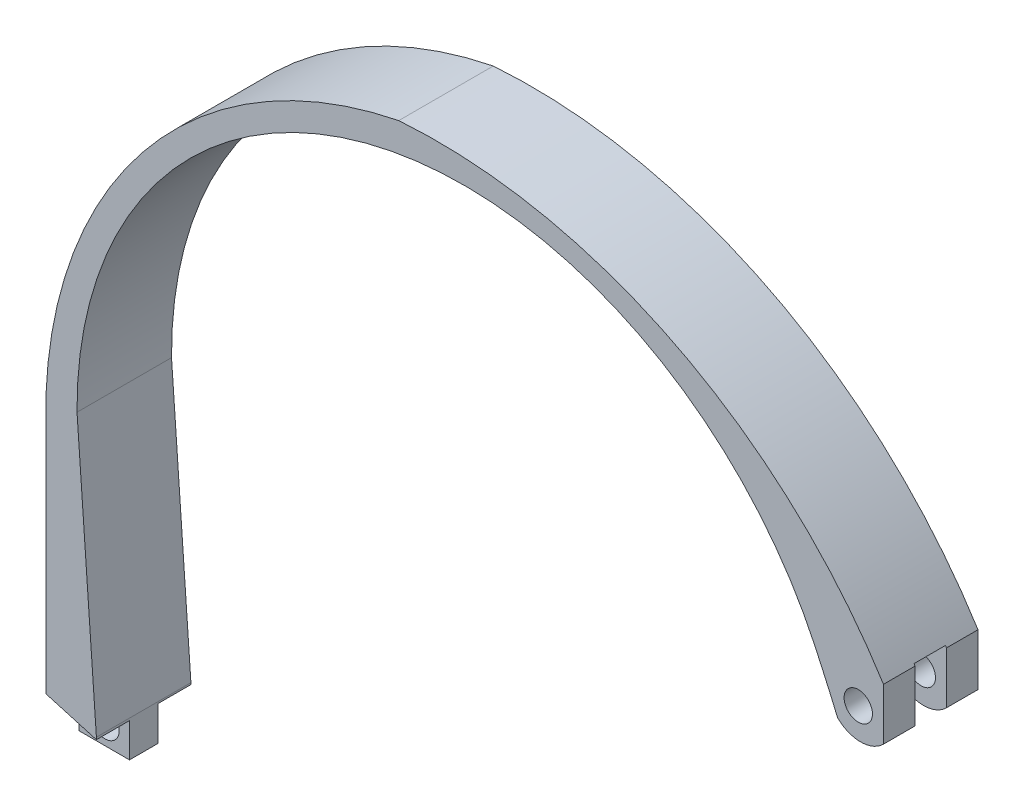
from build123d import *

# Parameters (mm, degrees)
SKETCH3_R           = 2.25
BOSS_EXTRUDE1_DEPTH = 15
CUT_EXTRUDE2_DEPTH  = 5.25
CUT_EXTRUDE3_DEPTH  = 5.25
SKETCH9_W           = 4.986330716
SKETCH9_H           = 10
CUT_EXTRUDE4_DEPTH  = 20


with BuildPart() as part:
    # Sketch3 → Boss-Extrude1 (new body)
    with BuildSketch(Plane.XY):
        with BuildLine():
            Line((-83.240837696, 45.680087808), (-86.318243263, 88.806933971))
            ThreePointArc((-86.318243263, 88.806933971), (-38.505178909, 149.199689366), (30.717635907, 115.412473794))
            ThreePointArc((30.717635907, 115.412473794), (32.594544712, 111.314313071), (34.392132503, 107.180744866))
            ThreePointArc((34.392132503, 107.180744866), (38.03694462, 105.671014255), (41.681756737, 107.180744866))
            Line((41.681756737, 107.180744866), (41.681756737, 115.412473794))
            ThreePointArc((41.681756737, 115.412473794), (8.630903534, 145.599759454), (-35.251645513, 154.428859194))
            ThreePointArc((-35.251645513, 154.428859194), (-74.611345825, 131.314701457), (-91.240837696, 88.806933971))
            Line((-91.240837696, 88.806933971), (-91.240837696, 47.654450262))
            Line((-91.240837696, 47.654450262), (-91.240837696, 39.931378559))
            Line((-91.240837696, 39.931378559), (-83.240837696, 39.931378559))
            Line((-83.240837696, 39.931378559), (-83.240837696, 45.680087808))
        make_face()
        with Locations((-87.125618482, 43.130480477)):
            Circle(SKETCH3_R, mode=Mode.SUBTRACT)
        with Locations((37.681756737, 110.446980465)):
            Circle(SKETCH3_R, mode=Mode.SUBTRACT)
    extrude(amount=-BOSS_EXTRUDE1_DEPTH)

    # Sketch5 → Cut-Extrude2 (cut)
    with BuildSketch(Plane.XY):
        Polygon((-91.240837696, 47.634728669), (-83.240837696, 45.336049347), (-83.240837696, 39.931378559), (-91.240837696, 39.931378559), align=None)
    extrude(amount=-CUT_EXTRUDE2_DEPTH, mode=Mode.SUBTRACT)

    # Sketch8 → Cut-Extrude3 (cut)
    with BuildSketch(Plane(origin=(0, 0, -15), x_dir=(-1, 0, 0), z_dir=(0, 0, -1))):
        Polygon((91.240837696, 47.718881947), (83.240837696, 45.410478658), (83.240837696, 39.931378559), (91.240837696, 39.931378559), align=None)
    extrude(amount=-CUT_EXTRUDE3_DEPTH, mode=Mode.SUBTRACT)

    # Sketch9 → Cut-Extrude4 (cut)
    with BuildSketch(Plane(origin=(41.681756737, 0, 0), x_dir=(0, 0, -1), z_dir=(1, 0, 0))):
        with Locations((7.506834642, 110.671014255)):
            Rectangle(SKETCH9_W, SKETCH9_H)
    extrude(amount=-CUT_EXTRUDE4_DEPTH, mode=Mode.SUBTRACT)


solid = part.part
